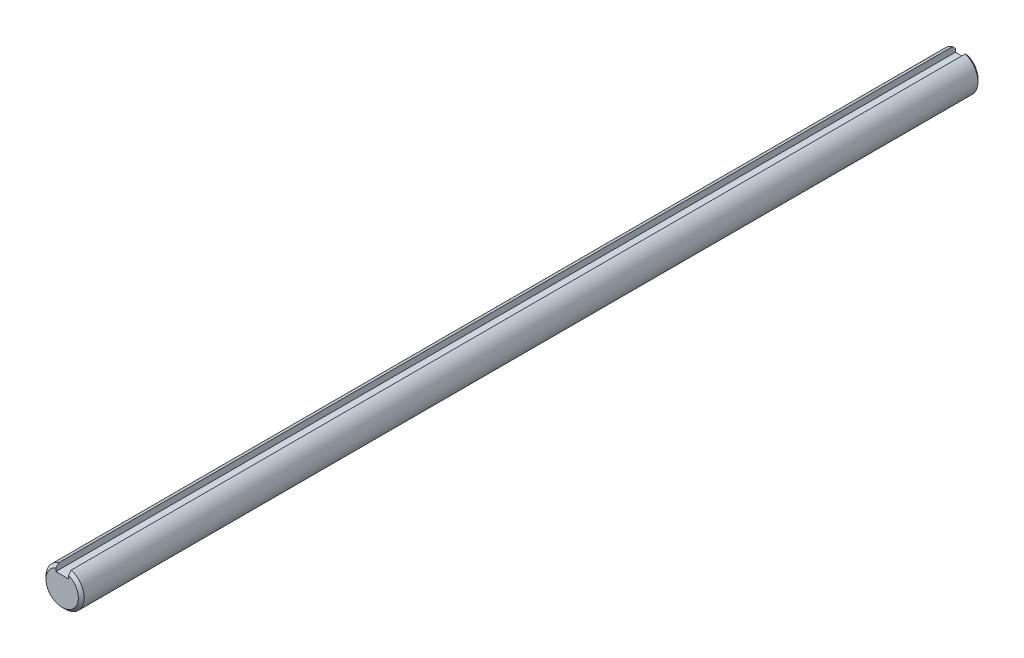
from build123d import *

# Parameters (mm, degrees)
SKETCH1_R           = 9
EXTRUDE1_DEPTH      = 212.5
CHAMFER1_SIZE       = 1.35
SKETCH3_W           = 6
SKETCH3_H           = 3.5
EXTRUDE2_DEPTH      = 213.5
EXTRUDE2_DEPTH_BACK = 213.5


with BuildPart() as part:
    # Sketch1 → Extrude1 (new body, symmetric)
    with BuildSketch(Plane.XY):
        Circle(SKETCH1_R)
    extrude(amount=EXTRUDE1_DEPTH, both=True)

    # Chamfer1
    chamfer1_edges = [part.edges().sort_by_distance(p)[0] for p in [
        (-9, 0, -212.5),
        (-9, 0, 212.5),
    ]]
    chamfer(chamfer1_edges, length=CHAMFER1_SIZE)

    # Sketch3 → Extrude2 (cut, two sides)
    with BuildSketch(Plane.XY) as extrude2_sk:
        with Locations((0, 7.25)):
            Rectangle(SKETCH3_W, SKETCH3_H)
    extrude(amount=EXTRUDE2_DEPTH, mode=Mode.SUBTRACT)
    extrude(extrude2_sk.sketch, amount=-EXTRUDE2_DEPTH_BACK, mode=Mode.SUBTRACT)


solid = part.part
